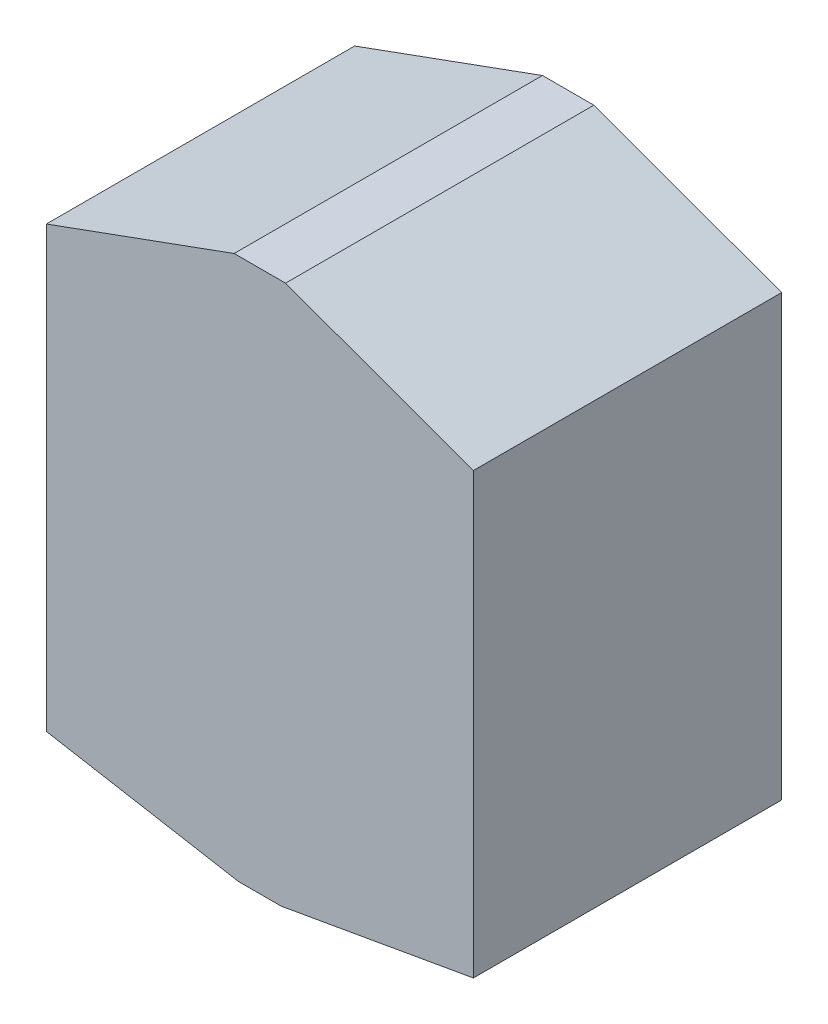
from build123d import *

# Parameters (mm, degrees)
BOSS_EXTRUDE1_DEPTH = 30


with BuildPart() as part:
    # Sketch1 → Boss-Extrude1 (new body)
    with BuildSketch(Plane.XY):
        with BuildLine():
            Line((0, 271.108554652), (-2.5, 271.108554652))
            Line((-2.5, 271.108554652), (-20.776742097, 264.45636455))
            Line((-20.776742097, 264.45636455), (-20.776742097, 221.692084557))
            Line((-20.776742097, 221.692084557), (-2.07767421, 218.394934374))
            Line((-2.07767421, 218.394934374), (0, 218.394934374))
            add(Edge.make_bspline(
                [(0, 218.394934374), (0, 235.966141134), (0, 253.537347893), (0, 271.108554652)],
                knots=[0.805688603, 0.805688603, 0.805688603, 0.805688603, 1, 1, 1, 1], degree=3))
        make_face()
        with BuildLine():
            Line((2.5, 271.108554652), (0, 271.108554652))
            add(Edge.make_bspline(
                [(0, 218.394934374), (0, 235.966141134), (0, 253.537347893), (0, 271.108554652)],
                knots=[0.805688603, 0.805688603, 0.805688603, 0.805688603, 1, 1, 1, 1], degree=3))
            Line((0, 218.394934374), (2.07767421, 218.394934374))
            Line((2.07767421, 218.394934374), (20.776742097, 221.692084557))
            Line((20.776742097, 221.692084557), (20.776742097, 264.45636455))
            Line((20.776742097, 264.45636455), (2.5, 271.108554652))
        make_face()
    extrude(amount=BOSS_EXTRUDE1_DEPTH)


solid = part.part
